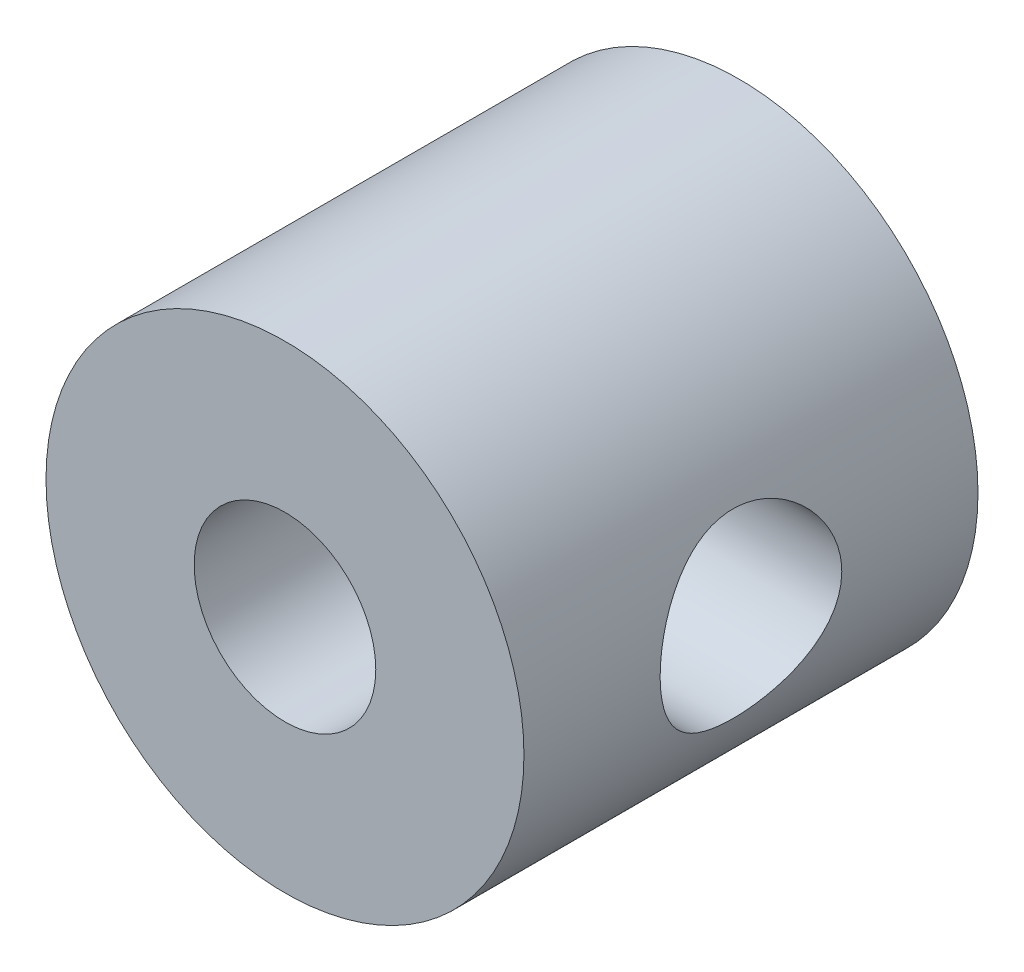
from build123d import *

# Parameters (mm, degrees)
SKETCH1_R               = 5
BOSS_EXTRUDE1_DEPTH     = 9.5
SKETCH2_R               = 1.9
CUT_EXTRUDE1_DEPTH      = 1
CUT_EXTRUDE1_DEPTH_BACK = 10.5
SKETCH3_R               = 1.9
CUT_EXTRUDE2_DEPTH      = 6
CUT_EXTRUDE2_DEPTH_BACK = 6


with BuildPart() as part:
    # Sketch1 → Boss-Extrude1 (new body)
    with BuildSketch(Plane.XY):
        Circle(SKETCH1_R)
    extrude(amount=BOSS_EXTRUDE1_DEPTH)

    # Sketch2 → Cut-Extrude1 (cut, two sides)
    with BuildSketch(Plane.XY.offset(9.5)) as cut_extrude1_sk:
        Circle(SKETCH2_R)
    extrude(amount=CUT_EXTRUDE1_DEPTH, mode=Mode.SUBTRACT)
    extrude(cut_extrude1_sk.sketch, amount=-CUT_EXTRUDE1_DEPTH_BACK, mode=Mode.SUBTRACT)

    # Sketch3 → Cut-Extrude2 (cut, two sides)
    with BuildSketch(Plane(origin=(0, 0, 0), x_dir=(0, 0, -1), z_dir=(1, 0, 0))) as cut_extrude2_sk:
        with Locations((-4.75, 0)):
            Circle(SKETCH3_R)
    extrude(amount=CUT_EXTRUDE2_DEPTH, mode=Mode.SUBTRACT)
    extrude(cut_extrude2_sk.sketch, amount=-CUT_EXTRUDE2_DEPTH_BACK, mode=Mode.SUBTRACT)


solid = part.part
